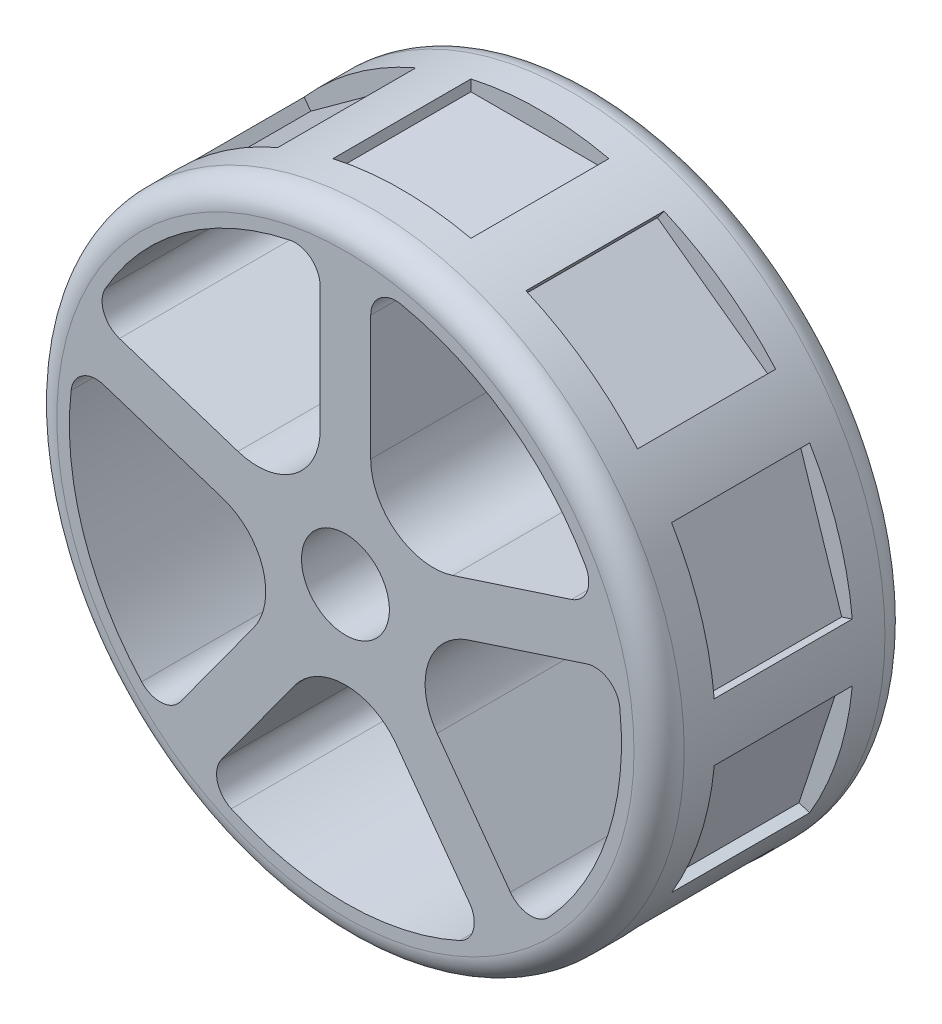
from build123d import *

# Parameters (mm, degrees)
SKETCH1_R           = 25
BOSS_EXTRUDE1_DEPTH = 10
FILLET1_R           = 2
FILLET2_R           = 2
FILLET3_R           = 5
CUT_EXTRUDE2_START  = 26
SKETCH4_W           = 11
SKETCH4_H           = 11
CUT_EXTRUDE2_DEPTH  = 2.5
CIRPATTERN1_COUNT   = 10
SKETCH2_R           = 3.5
CUT_EXTRUDE1_DEPTH  = 21


with BuildPart() as part:
    # Sketch1 → Boss-Extrude1 (new body, symmetric)
    with BuildSketch(Plane.XY):
        Circle(SKETCH1_R)
        with BuildLine():
            Line((-2.01454878, 21.907569313), (-2.01454878, 2.772788518))
            Line((-2.01454878, 2.772788518), (-20.212806743, 8.685760967))
            ThreePointArc((-20.212806743, 8.685760967), (-12.93127555, 17.798373876), (-2.01454878, 21.907569313))
        make_face(mode=Mode.SUBTRACT)
        with BuildLine():
            Line((2.01454878, 21.907569313), (2.01454878, 2.772788518))
            Line((2.01454878, 2.772788518), (20.212806743, 8.685760967))
            ThreePointArc((20.212806743, 8.685760967), (12.93127555, 17.798373876), (2.01454878, 21.907569313))
        make_face(mode=Mode.SUBTRACT)
        with BuildLine():
            Line((21.45786636, 4.853861479), (3.259608397, -1.05911097))
            Line((3.259608397, -1.05911097), (14.506750355, -16.539473817))
            ThreePointArc((14.506750355, -16.539473817), (20.923243358, -6.798373876), (21.45786636, 4.853861479))
        make_face(mode=Mode.SUBTRACT)
        with BuildLine():
            Line((11.247141957, -18.907717943), (0, -3.427355096))
            Line((0, -3.427355096), (-11.247141957, -18.907717943))
            ThreePointArc((-11.247141957, -18.907717943), (0, -22), (11.247141957, -18.907717943))
        make_face(mode=Mode.SUBTRACT)
        with BuildLine():
            Line((-14.506750355, -16.539473817), (-3.259608397, -1.05911097))
            Line((-3.259608397, -1.05911097), (-21.45786636, 4.853861479))
            ThreePointArc((-21.45786636, 4.853861479), (-20.923243358, -6.798373876), (-14.506750355, -16.539473817))
        make_face(mode=Mode.SUBTRACT)
    extrude(amount=BOSS_EXTRUDE1_DEPTH, both=True)

    # Fillet1
    fillet1_edges = [part.edges().sort_by_distance(p)[0] for p in [
        (-25, 0, -10),
        (-25, 0, 10),
    ]]
    fillet(fillet1_edges, radius=FILLET1_R)

    # Fillet2
    fillet2_edges = [part.edges().sort_by_distance(p)[0] for p in [
        (-20.212806743, 8.685760967, 0),
        (-2.01454878, 21.907569313, 0),
        (-14.506750355, -16.539473817, 0),
        (-21.45786636, 4.853861479, 0),
        (11.247141957, -18.907717943, 0),
        (-11.247141957, -18.907717943, 0),
        (21.45786636, 4.853861479, 0),
        (14.506750355, -16.539473817, 0),
        (2.01454878, 21.907569313, 0),
        (20.212806743, 8.685760967, 0),
    ]]
    fillet(fillet2_edges, radius=FILLET2_R)

    # Fillet3
    fillet3_edges = [part.edges().sort_by_distance(p)[0] for p in [
        (-2.01454878, 2.772788518, 0),
        (-3.259608397, -1.05911097, 0),
        (0, -3.427355096, 0),
        (3.259608397, -1.05911097, 0),
        (2.01454878, 2.772788518, 0),
    ]]
    fillet(fillet3_edges, radius=FILLET3_R)

    # Sketch4 → Cut-Extrude2 (cut)
    with BuildSketch(Plane(origin=(0, 0, 0), x_dir=(1, 0, 0), z_dir=(0, 1, 0)).offset(CUT_EXTRUDE2_START)):
        Rectangle(SKETCH4_W, SKETCH4_H)
    cut_extrude2 = extrude(amount=-CUT_EXTRUDE2_DEPTH, mode=Mode.SUBTRACT)

    # CirPattern1: Cut-Extrude2 ×10 about axis
    cirpattern1_axis = Axis((0, 0, 0), (0, 0, 1))
    for i in range(1, CIRPATTERN1_COUNT):
        add(cut_extrude2.rotate(cirpattern1_axis, i * 360 / CIRPATTERN1_COUNT), mode=Mode.SUBTRACT)

    # Sketch2 → Cut-Extrude1 (cut, through all)
    with BuildSketch(Plane(origin=(0, 0, -10), x_dir=(-1, 0, 0), z_dir=(0, 0, -1))):
        Circle(SKETCH2_R)
    extrude(amount=-CUT_EXTRUDE1_DEPTH, mode=Mode.SUBTRACT)


solid = part.part
